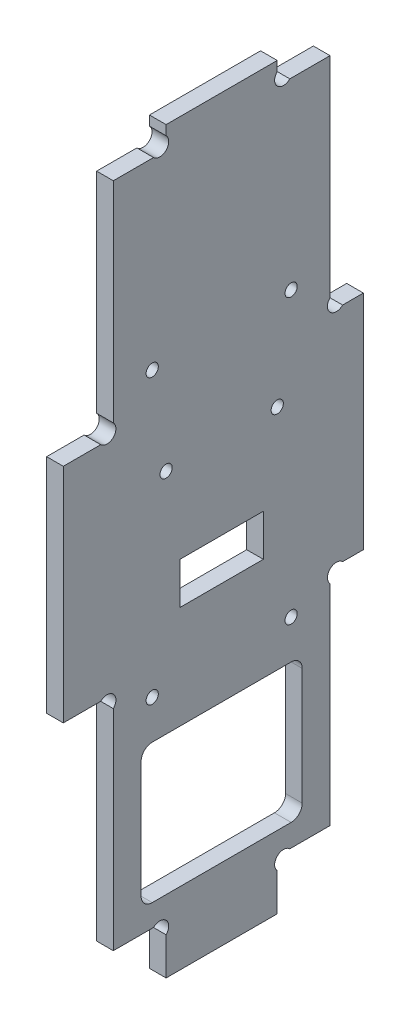
from build123d import *

# Parameters (mm, degrees)
EXTRUSION1_DEPTH        = 3
ESQUISSE2_R             = 1.1
ESQUISSE2_W             = 29
ESQUISSE2_H             = 25
ENL_V_MAT_EXTRU_1_DEPTH = 4
CONG_1_R                = 2
ESQUISSE3_W             = 15
ESQUISSE3_H             = 7.5
ENL_V_MAT_EXTRU_2_DEPTH = 4
ESQUISSE4_R             = 1.1
ENL_V_MAT_EXTRU_3_DEPTH = 4


with BuildPart() as part:
    # Esquisse1 → Extrusion1 (new body)
    with BuildSketch(Plane(origin=(0, 0, 0), x_dir=(0, 0, -1), z_dir=(1, 0, 0))):
        with BuildLine():
            Line((18.5, 6.7372583), (18.5, 0))
            Line((18.5, 0), (38.5, 0))
            Line((38.5, 0), (38.5, 6.7372583))
            ThreePointArc((38.5, 6.7372583), (38.5, 9), (40.7627417, 9))
            Line((40.7627417, 9), (48, 9))
            Line((48, 9), (48, 46.7372583))
            ThreePointArc((48, 46.7372583), (48, 49), (50.2627417, 49))
            Line((50.2627417, 49), (54, 49))
            Line((54, 49), (54, 89))
            Line((54, 89), (50.2627417, 89))
            ThreePointArc((50.2627417, 89), (48, 89), (48, 91.2627417))
            Line((48, 91.2627417), (48, 129))
            Line((48, 129), (40.7627417, 129))
            ThreePointArc((40.7627417, 129), (38.5, 129), (38.5, 131.2627417))
            Line((38.5, 131.2627417), (38.5, 133))
            Line((38.5, 133), (18.5, 133))
            Line((18.5, 133), (18.5, 131.2627417))
            ThreePointArc((18.5, 131.2627417), (18.5, 129), (16.2372583, 129))
            Line((16.2372583, 129), (9, 129))
            Line((9, 129), (9, 91.2627417))
            ThreePointArc((9, 91.2627417), (9, 89), (6.7372583, 89))
            Line((6.7372583, 89), (0, 89))
            Line((0, 89), (0, 49))
            Line((0, 49), (6.7372583, 49))
            ThreePointArc((6.7372583, 49), (9, 49), (9, 46.7372583))
            Line((9, 46.7372583), (9, 9))
            Line((9, 9), (16.2372583, 9))
            ThreePointArc((16.2372583, 9), (18.5, 9), (18.5, 6.7372583))
        make_face()
    extrude(amount=EXTRUSION1_DEPTH)

    # Esquisse2 → Enlèv. mat.-Extru.1 (cut, through all)
    with BuildSketch(Plane.ZY):
        with Locations((-38.5, 79)):
            Circle(ESQUISSE2_R)
        with Locations((-18.5, 79)):
            Circle(ESQUISSE2_R)
        with Locations((-28.5, 25.5)):
            Rectangle(ESQUISSE2_W, ESQUISSE2_H)
    extrude(amount=-ENL_V_MAT_EXTRU_1_DEPTH, mode=Mode.SUBTRACT)

    # Congé1
    cong_1_edges = [part.edges().sort_by_distance(p)[0] for p in [
        (1.5, 38, -14),
        (1.5, 13, -14),
        (1.5, 13, -43),
        (1.5, 38, -43),
    ]]
    fillet(cong_1_edges, radius=CONG_1_R)

    # Esquisse3 → Enlèv. mat.-Extru.2 (cut, through all)
    with BuildSketch(Plane.ZY):
        with Locations((-28.5, 60.25)):
            Rectangle(ESQUISSE3_W, ESQUISSE3_H)
    extrude(amount=-ENL_V_MAT_EXTRU_2_DEPTH, mode=Mode.SUBTRACT)

    # Esquisse4 → Enlèv. mat.-Extru.3 (cut, through all)
    with BuildSketch(Plane.ZY):
        with Locations((-41, 96)):
            Circle(ESQUISSE4_R)
        with Locations((-16, 96)):
            Circle(ESQUISSE4_R)
        with Locations((-41, 45)):
            Circle(ESQUISSE4_R)
        with Locations((-16, 45)):
            Circle(ESQUISSE4_R)
    extrude(amount=-ENL_V_MAT_EXTRU_3_DEPTH, mode=Mode.SUBTRACT)


solid = part.part
